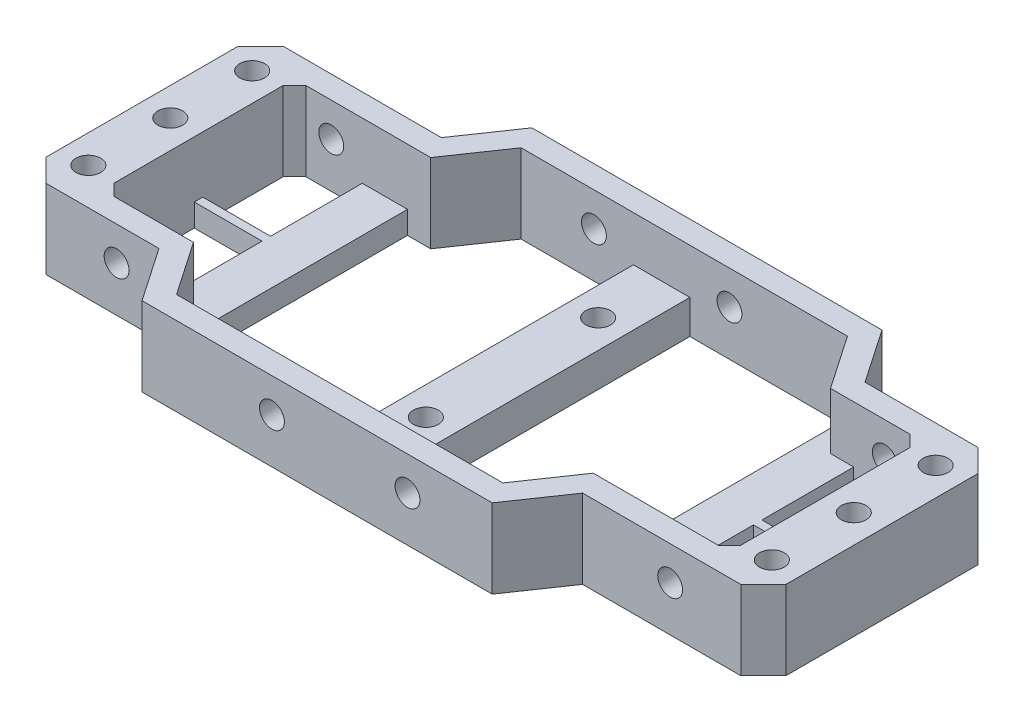
from build123d import *

# Parameters (mm, degrees)
BOSS_EXTRUDE1_DEPTH = 14
CUT_EXTRUDE1_REACH  = 16
SKETCH2_R           = 2.2
SKETCH5_R           = 2.2
CUT_EXTRUDE2_DEPTH  = 62
BOSS_EXTRUDE2_REACH = 59
SKETCH6_W           = 10
SKETCH6_H           = 6
BOSS_EXTRUDE3_DEPTH = 4
CUT_EXTRUDE3_REACH  = 16
SKETCH8_R           = 2.2
CHAMFER1_SIZE       = 4
CHAMFER2_SIZE       = 2


with BuildPart() as part:
    # Sketch1 → Boss-Extrude1 (new body)
    with BuildSketch(Plane(origin=(0, 0, 0), x_dir=(1, 0, 0), z_dir=(0, 1, 0))):
        Polygon((-104.176003517, -21), (-104.176003517, 21), (-72.176003517, 21), (-65.676003517, 30.5), (-3.676003517, 30.5), (2.823996483, 21), (26.823996483, 21), (26.823996483, -21), (-5.176003517, -21), (-11.676003517, -30.5), (-73.676003517, -30.5), (-80.176003517, -21), align=None)
        Polygon((-94.176003517, -17), (-94.176003517, 17), (-70.066165861, 17), (-63.566165861, 26.5), (-5.785841173, 26.5), (0.714158827, 17), (16.823996483, 17), (16.823996483, -17), (-7.285841173, -17), (-13.785841173, -26.5), (-71.566165861, -26.5), (-78.066165861, -17), align=None, mode=Mode.SUBTRACT)
    extrude(amount=BOSS_EXTRUDE1_DEPTH)

    # Sketch2 → Cut-Extrude1 (cut, up to next)
    with BuildSketch(Plane(origin=(0, 0, 0), x_dir=(-1, 0, 0), z_dir=(0, -1, 0)), mode=Mode.PRIVATE) as cut_extrude1_sk1:
        with Locations(Location((99.176003517, 14.5, 0), (0, 0, 90))):  # turned: the seam where the file's is
            Circle(SKETCH2_R)
    cut_extrude1_tool1 = extrude(cut_extrude1_sk1.sketch, amount=-CUT_EXTRUDE1_REACH, mode=Mode.PRIVATE) & part.part
    add(cut_extrude1_tool1.solids().sort_by_distance((-99.176004, 0, -14.5))[0], mode=Mode.SUBTRACT)
    # Sketch2 → Cut-Extrude1 (cut, up to next)
    with BuildSketch(Plane(origin=(0, 0, 0), x_dir=(-1, 0, 0), z_dir=(0, -1, 0)), mode=Mode.PRIVATE) as cut_extrude1_sk2:
        with Locations(Location((99.176003517, 0, 0), (0, 0, 90))):  # turned: the seam where the file's is
            Circle(SKETCH2_R)
    cut_extrude1_tool2 = extrude(cut_extrude1_sk2.sketch, amount=-CUT_EXTRUDE1_REACH, mode=Mode.PRIVATE) & part.part
    add(cut_extrude1_tool2.solids().sort_by_distance((-99.176004, 0, 0))[0], mode=Mode.SUBTRACT)
    # Sketch2 → Cut-Extrude1 (cut, up to next)
    with BuildSketch(Plane(origin=(0, 0, 0), x_dir=(-1, 0, 0), z_dir=(0, -1, 0)), mode=Mode.PRIVATE) as cut_extrude1_sk3:
        with Locations(Location((99.176003517, -14.5, 0), (0, 0, 90))):  # turned: the seam where the file's is
            Circle(SKETCH2_R)
    cut_extrude1_tool3 = extrude(cut_extrude1_sk3.sketch, amount=-CUT_EXTRUDE1_REACH, mode=Mode.PRIVATE) & part.part
    add(cut_extrude1_tool3.solids().sort_by_distance((-99.176004, 0, 14.5))[0], mode=Mode.SUBTRACT)
    # Sketch2 → Cut-Extrude1 (cut, up to next)
    with BuildSketch(Plane(origin=(0, 0, 0), x_dir=(-1, 0, 0), z_dir=(0, -1, 0)), mode=Mode.PRIVATE) as cut_extrude1_sk4:
        with Locations(Location((-21.823996483, -14.5, 0), (0, 0, 90))):  # turned: the seam where the file's is
            Circle(SKETCH2_R)
    cut_extrude1_tool4 = extrude(cut_extrude1_sk4.sketch, amount=-CUT_EXTRUDE1_REACH, mode=Mode.PRIVATE) & part.part
    add(cut_extrude1_tool4.solids().sort_by_distance((21.823996, 0, 14.5))[0], mode=Mode.SUBTRACT)
    # Sketch2 → Cut-Extrude1 (cut, up to next)
    with BuildSketch(Plane(origin=(0, 0, 0), x_dir=(-1, 0, 0), z_dir=(0, -1, 0)), mode=Mode.PRIVATE) as cut_extrude1_sk5:
        with Locations(Location((-21.823996483, 0, 0), (0, 0, 90))):  # turned: the seam where the file's is
            Circle(SKETCH2_R)
    cut_extrude1_tool5 = extrude(cut_extrude1_sk5.sketch, amount=-CUT_EXTRUDE1_REACH, mode=Mode.PRIVATE) & part.part
    add(cut_extrude1_tool5.solids().sort_by_distance((21.823996, 0, 0))[0], mode=Mode.SUBTRACT)
    # Sketch2 → Cut-Extrude1 (cut, up to next)
    with BuildSketch(Plane(origin=(0, 0, 0), x_dir=(-1, 0, 0), z_dir=(0, -1, 0)), mode=Mode.PRIVATE) as cut_extrude1_sk6:
        with Locations(Location((-21.823996483, 14.5, 0), (0, 0, 90))):  # turned: the seam where the file's is
            Circle(SKETCH2_R)
    cut_extrude1_tool6 = extrude(cut_extrude1_sk6.sketch, amount=-CUT_EXTRUDE1_REACH, mode=Mode.PRIVATE) & part.part
    add(cut_extrude1_tool6.solids().sort_by_distance((21.823996, 0, -14.5))[0], mode=Mode.SUBTRACT)

    # Sketch5 → Cut-Extrude2 (cut, through all)
    with BuildSketch(Plane(origin=(0, 0, -30.5), x_dir=(-1, 0, 0), z_dir=(0, 0, -1))):
        with Locations((50.676003517, 8)):
            Circle(SKETCH5_R)
        with Locations((26.676003517, 8)):
            Circle(SKETCH5_R)
        with Locations(Location((87.676003517, 8, 0), (0, 0, 180))):  # turned: the seam where the file's is
            Circle(SKETCH5_R)
        with Locations(Location((-10.323996483, 8, 0), (0, 0, 180))):  # turned: the seam where the file's is
            Circle(SKETCH5_R)
    extrude(amount=-CUT_EXTRUDE2_DEPTH, mode=Mode.SUBTRACT)

    # Sketch6 → Boss-Extrude2 (add, up to next)
    with BuildSketch(Plane(origin=(0, 0, 26.5), x_dir=(-1, 0, 0), z_dir=(0, 0, -1)), mode=Mode.PRIVATE) as boss_extrude2_sk1:
        with Locations((38.676003517, 3)):
            Rectangle(SKETCH6_W, SKETCH6_H)
    boss_extrude2_tool1 = extrude(boss_extrude2_sk1.sketch, amount=BOSS_EXTRUDE2_REACH, mode=Mode.PRIVATE) - part.part
    add(boss_extrude2_tool1.solids().sort_by_distance((-38.676004, 3, 26.5))[0])

    # Sketch7 → Boss-Extrude3 (add)
    with BuildSketch(Plane.XZ):
        Polygon((-78.066165861, 17), (-82.176003517, 17), (-82.176003517, 0.75), (-94.176003517, 0.75), (-94.176003517, -0.75), (-82.176003517, -0.75), (-82.176003517, -17), (-74.176003517, -17), (-74.176003517, 22.685621887), align=None)
        Polygon((4.823996483, -17), (4.823996483, -0.75), (16.823996483, -0.75), (16.823996483, 0.75), (4.823996483, 0.75), (4.823996483, 17), (-3.176003517, 17), (-3.176003517, -22.685621887), (0.714158827, -17), align=None)
    extrude(amount=-BOSS_EXTRUDE3_DEPTH)

    # Sketch8 → Cut-Extrude3 (cut, up to next)
    with BuildSketch(Plane(origin=(0, 0, 0), x_dir=(-1, 0, 0), z_dir=(0, -1, 0)), mode=Mode.PRIVATE) as cut_extrude3_sk1:
        with Locations(Location((38.676003517, -15.25, 0), (0, 0, 90))):  # turned: the seam where the file's is
            Circle(SKETCH8_R)
    cut_extrude3_tool1 = extrude(cut_extrude3_sk1.sketch, amount=-CUT_EXTRUDE3_REACH, mode=Mode.PRIVATE) & part.part
    add(cut_extrude3_tool1.solids().sort_by_distance((-38.676004, 0, 15.25))[0], mode=Mode.SUBTRACT)
    # Sketch8 → Cut-Extrude3 (cut, up to next)
    with BuildSketch(Plane(origin=(0, 0, 0), x_dir=(-1, 0, 0), z_dir=(0, -1, 0)), mode=Mode.PRIVATE) as cut_extrude3_sk2:
        with Locations(Location((38.676003517, 15.25, 0), (0, 0, 90))):  # turned: the seam where the file's is
            Circle(SKETCH8_R)
    cut_extrude3_tool2 = extrude(cut_extrude3_sk2.sketch, amount=-CUT_EXTRUDE3_REACH, mode=Mode.PRIVATE) & part.part
    add(cut_extrude3_tool2.solids().sort_by_distance((-38.676004, 0, -15.25))[0], mode=Mode.SUBTRACT)

    # Chamfer1
    chamfer1_edges = [part.edges().sort_by_distance(p)[0] for p in [
        (-104.176003517, 7, 21),
        (-104.176003517, 7, -21),
        (26.823996483, 7, -21),
        (26.823996483, 7, 21),
    ]]
    chamfer(chamfer1_edges, length=CHAMFER1_SIZE)

    # Chamfer2
    chamfer2_edges = [part.edges().sort_by_distance(p)[0] for p in [
        (-94.176003517, 7, 17),
        (16.823996483, 7, 17),
        (16.823996483, 7, -17),
        (-94.176003517, 7, -17),
    ]]
    chamfer(chamfer2_edges, length=CHAMFER2_SIZE)


solid = part.part
